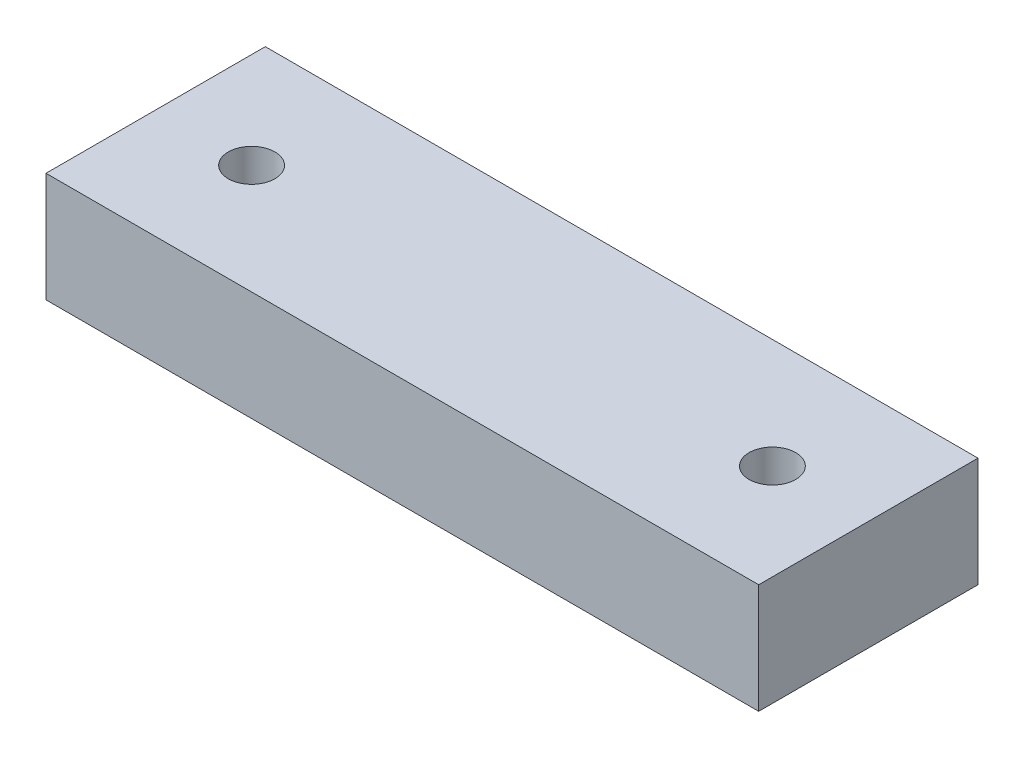
from build123d import *

# Parameters (mm, degrees)
SKETCH_1_W              = 130
SKETCH_1_H              = 40
EXTRUDE_1_DEPTH         = 20
HOLE_WIZARD_M10_1_D     = 8.5
HOLE_WIZARD_M10_1_DEPTH = 24.5
HOLE_WIZARD_M10_1_TIP   = 2.553657631


with BuildPart() as part:
    # 草图1 → 凸台-拉伸1 (new body)
    with BuildSketch(Plane(origin=(0, 0, 0), x_dir=(1, 0, 0), z_dir=(0, 1, 0))):
        Rectangle(SKETCH_1_W, SKETCH_1_H)
    extrude(amount=EXTRUDE_1_DEPTH)

    # M10 螺纹孔1
    with Locations(Plane(origin=(0, 20, 0), x_dir=(1, 0, 0), z_dir=(0, 1, 0))):
        with Locations((47.5, 0), (-47.5, 0)):
            Hole(HOLE_WIZARD_M10_1_D / 2, depth=HOLE_WIZARD_M10_1_DEPTH)
            with Locations((0, 0, -(HOLE_WIZARD_M10_1_DEPTH + HOLE_WIZARD_M10_1_TIP / 2))):  # 118° drill point
                Cone(0, HOLE_WIZARD_M10_1_D / 2, HOLE_WIZARD_M10_1_TIP, mode=Mode.SUBTRACT)


solid = part.part
